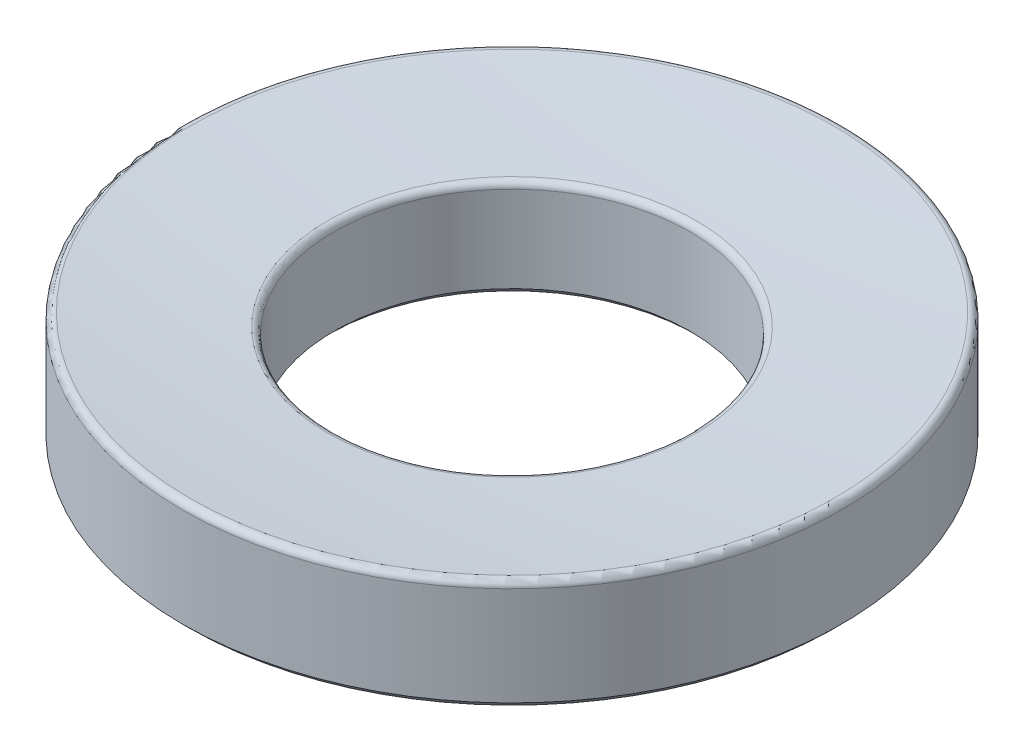
from build123d import *

# Parameters (mm, degrees)
FILLET3_R     = 0.254
CHAMFER2_SIZE = 0.254


with BuildPart() as part:
    # Sketch1 → Concave Revolve (revolve)
    with BuildSketch(Plane.XY, mode=Mode.PRIVATE) as concave_revolve_sk:
        with BuildLine():
            Line((6.858, -110.269336068), (12.7, -110.269336068))
            Line((12.7, -110.269336068), (12.7, -105.921350067))
            ThreePointArc((12.7, -105.921350067), (9.782698924, -106.23050975), (6.858, -106.459336068))
            Line((6.858, -106.459336068), (6.858, -110.269336068))
        make_face()
    revolve(concave_revolve_sk.sketch.rotate(Axis((0, 0, 0), (0, -1, 0)), 90), axis=Axis((0, 0, 0), (0, -1, 0)))  # turned: the seam where the file's is

    # Fillet3
    fillet3_edges = [part.edges().sort_by_distance(p)[0] for p in [
        (0, -106.459336068, -6.858),
        (0, -105.921350067, -12.7),
    ]]
    fillet(fillet3_edges, radius=FILLET3_R)

    # Chamfer2
    chamfer2_edges = [part.edges().sort_by_distance(p)[0] for p in [
        (0, -110.269336068, -12.7),
        (0, -110.269336068, -6.858),
    ]]
    chamfer(chamfer2_edges, length=CHAMFER2_SIZE)


solid = part.part
